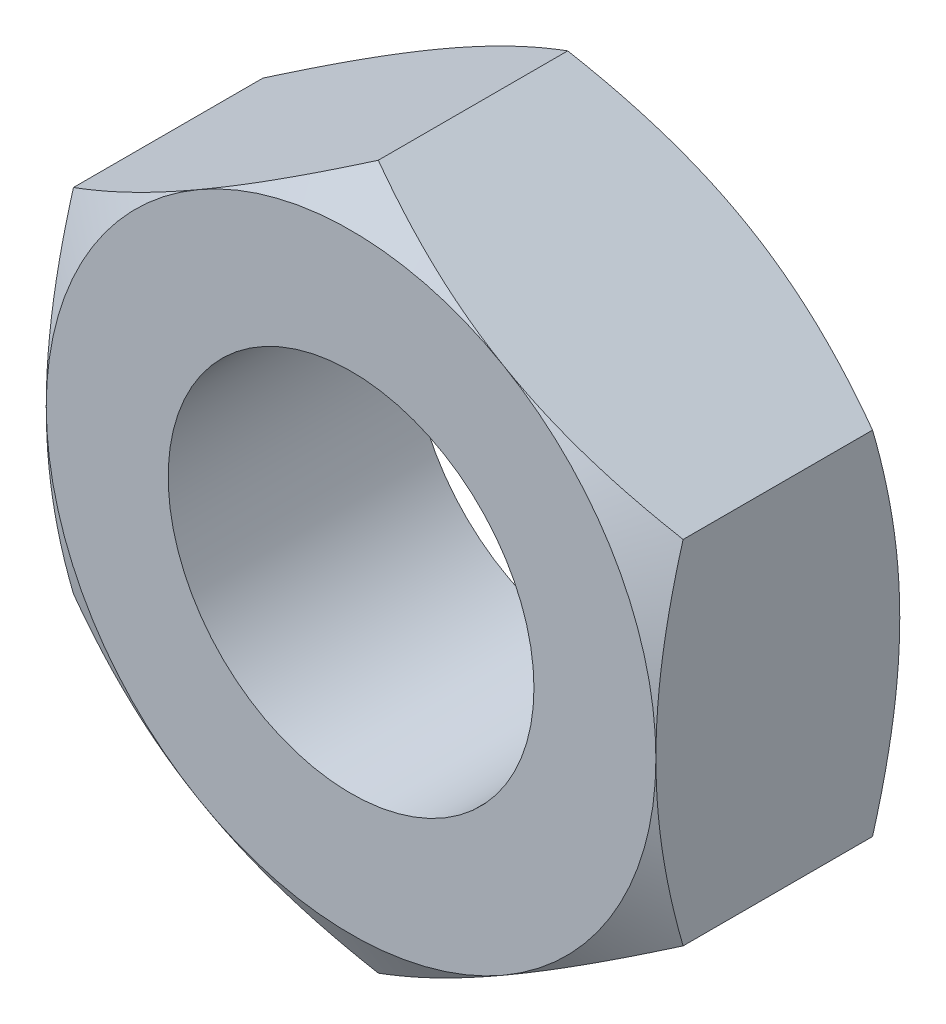
from build123d import *

# Parameters (mm, degrees)
SZKIC1_R                    = 3
DODANIE_WYCI_GNI_CIE1_DEPTH = 4


with BuildPart() as part:
    # Szkic1 → Dodanie-wyciągnięcie1 (new body)
    with BuildSketch(Plane.XY):
        Polygon((5, 2.886751346), (0, 5.773502692), (-5, 2.886751346), (-5, -2.886751346), (0, -5.773502692), (5, -2.886751346), align=None)
        Circle(SZKIC1_R, mode=Mode.SUBTRACT)
    extrude(amount=DODANIE_WYCI_GNI_CIE1_DEPTH)

    # Szkic2 → Wycięcie-obrót1 (revolve, cut)
    with BuildSketch(Plane(origin=(0, 0, 0), x_dir=(1, 0, 0), z_dir=(0, 1, 0))):
        Polygon((-8.464101615, -4), (-5, -4), (-8.464101615, -2), align=None)
        Polygon((-8.464101615, -2), (-5, 0), (-8.464101615, 0), align=None)
    revolve(axis=Axis((0, 0, 9.891098034), (0, 0, -1)), mode=Mode.SUBTRACT)


solid = part.part
